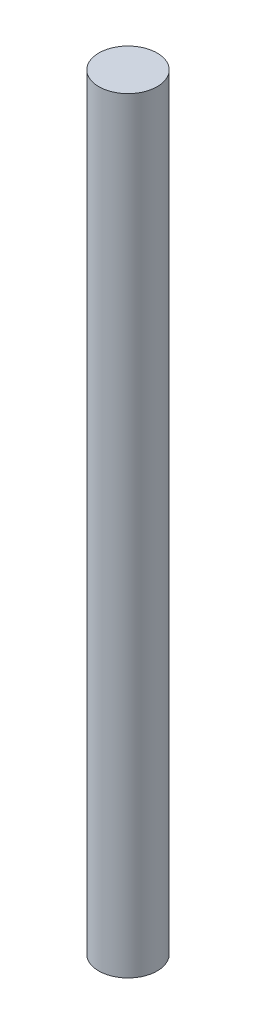
from build123d import *

# Parameters (mm, degrees)
SKETCH_1_W = 4
SKETCH_1_H = 105


with BuildPart() as part:
    # 草图1 → 旋转1 (revolve)
    with BuildSketch(Plane(origin=(0, 0, 0), x_dir=(-1, 0, 0), z_dir=(0, 0, -1))):
        with Locations((-142, -52.5)):
            Rectangle(SKETCH_1_W, SKETCH_1_H)
    revolve(axis=Axis((140, -105, 0), (0, 1, 0)))


solid = part.part
